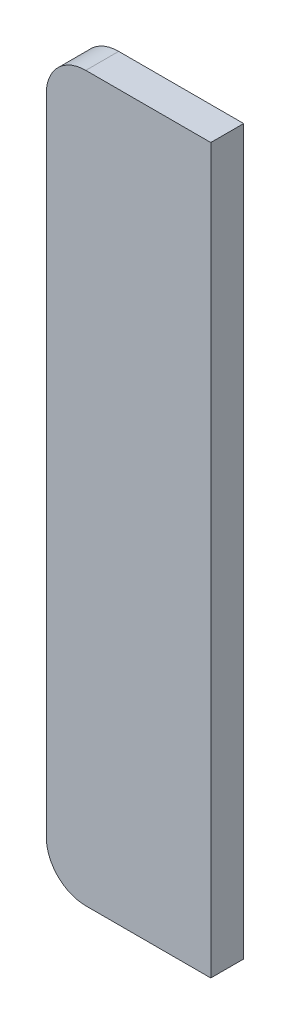
from build123d import *

# Parameters (mm, degrees)
SKETCH1_W           = 125
SKETCH1_H           = 550
BOSS_EXTRUDE1_DEPTH = 25
FILLET4_R           = 30
FILLET5_R           = 30


with BuildPart() as part:
    # Sketch1 → Boss-Extrude1 (new body)
    with BuildSketch(Plane.XY):
        with Locations((62.5, 275)):
            Rectangle(SKETCH1_W, SKETCH1_H)
    extrude(amount=BOSS_EXTRUDE1_DEPTH)

    # Fillet4
    fillet4_edges = [part.edges().sort_by_distance(p)[0] for p in [
        (0, 550, 12.5),
    ]]
    fillet(fillet4_edges, radius=FILLET4_R)

    # Fillet5
    fillet5_edges = [part.edges().sort_by_distance(p)[0] for p in [
        (0, 0, 12.5),
    ]]
    fillet(fillet5_edges, radius=FILLET5_R)


solid = part.part
